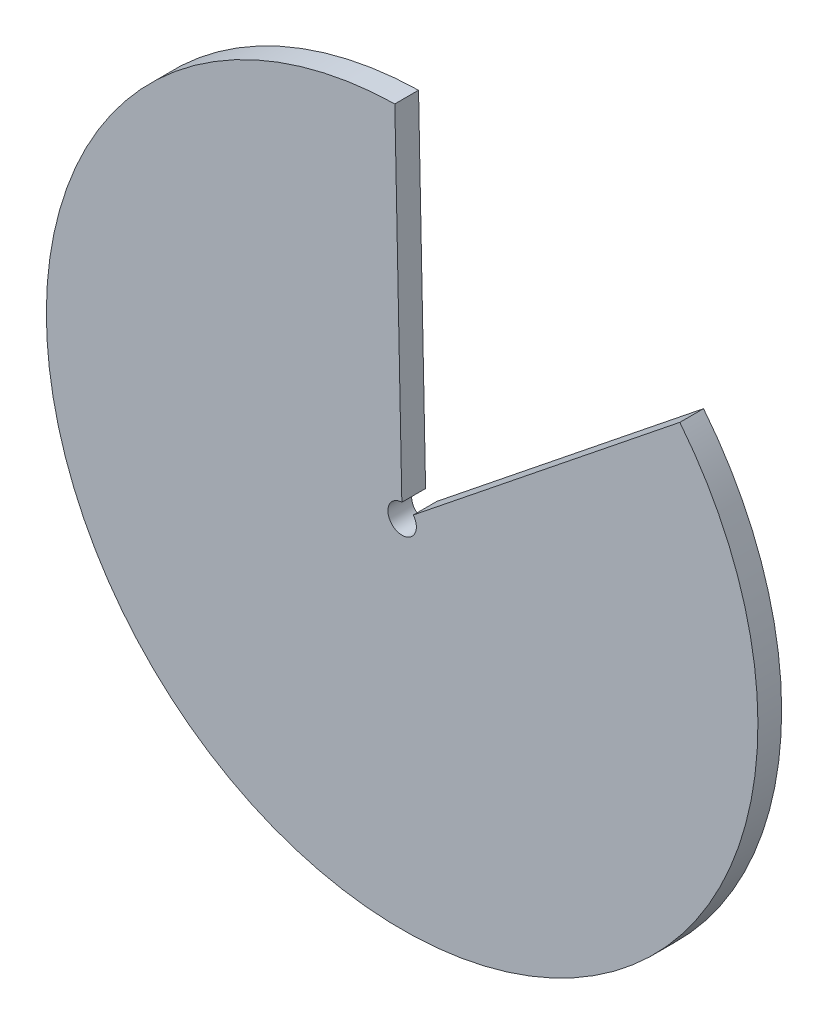
from build123d import *

# Parameters (mm, degrees)
SKETCH1_R           = 38.1
BOSS_EXTRUDE1_DEPTH = 2.54
CUT_EXTRUDE1_DEPTH  = 2.54
SKETCH3_R           = 1.524
CUT_EXTRUDE2_DEPTH  = 2.54


with BuildPart() as part:
    # Sketch1 → Boss-Extrude1 (new body)
    with BuildSketch(Plane.XY):
        Circle(SKETCH1_R)
    extrude(amount=BOSS_EXTRUDE1_DEPTH)

    # Sketch2 → Cut-Extrude1 (cut)
    with BuildSketch(Plane.XY.offset(2.54)):
        with BuildLine():
            Line((0, 0), (-0.783784717, 38.091937225))
            ThreePointArc((-0.783784717, 38.091937225), (16.139227372, 34.512828627), (29.735705264, 23.820114031))
            Line((29.735705264, 23.820114031), (0, 0))
        make_face()
    extrude(amount=-CUT_EXTRUDE1_DEPTH, mode=Mode.SUBTRACT)

    # Sketch3 → Cut-Extrude2 (cut)
    with BuildSketch(Plane.XY.offset(2.54)):
        Circle(SKETCH3_R)
    extrude(amount=-CUT_EXTRUDE2_DEPTH, mode=Mode.SUBTRACT)


solid = part.part
